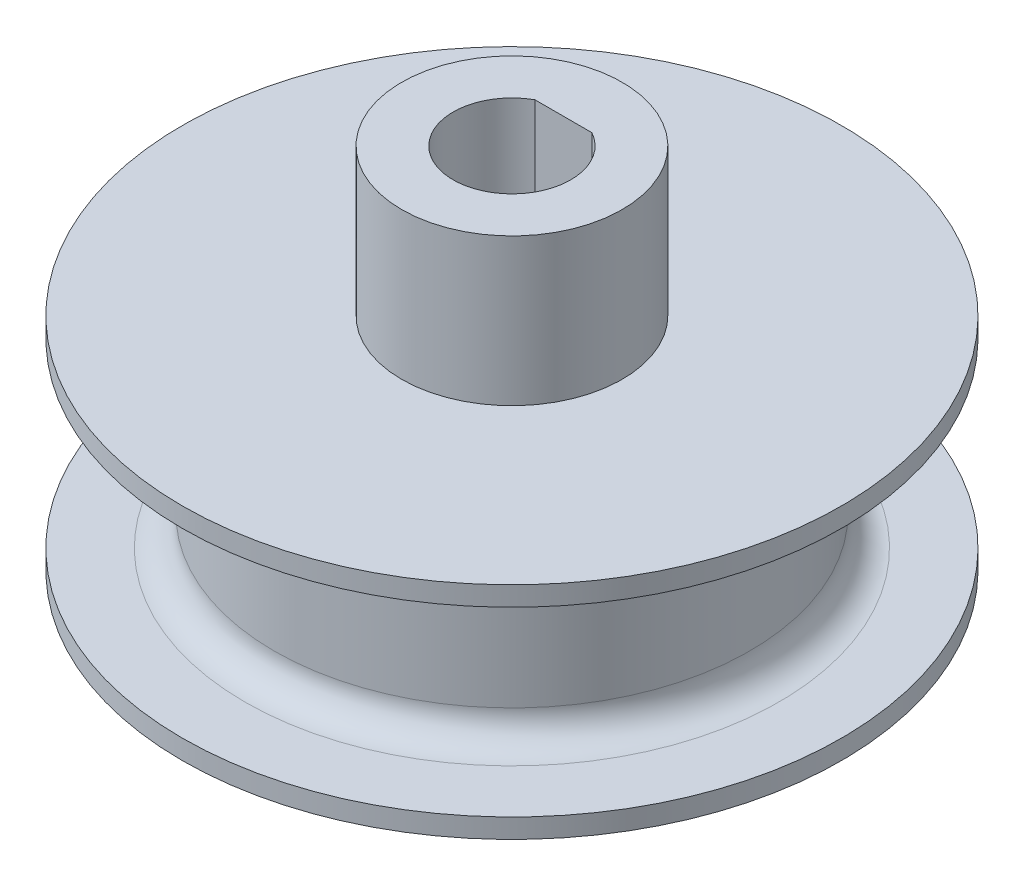
from build123d import *

# Parameters (mm, degrees)
SKETCH2_R           = 15
BOSS_EXTRUDE1_DEPTH = 7.5
SKETCH4_R           = 7.5
BOSS_EXTRUDE2_DEPTH = 10


with BuildPart() as part:
    # Sketch2 → Boss-Extrude1 (new body, symmetric)
    with BuildSketch(Plane(origin=(0, 0, 0), x_dir=(1, 0, 0), z_dir=(0, 1, 0))):
        Circle(SKETCH2_R)
        with BuildLine():
            ThreePointArc((1.936491673, 3.5), (0, -4), (-1.936491673, 3.5))
            Line((-1.936491673, 3.5), (1.936491673, 3.5))
        make_face(mode=Mode.SUBTRACT)
    extrude(amount=BOSS_EXTRUDE1_DEPTH, both=True)

    # Sketch3 → Revolve1 (revolve)
    with BuildSketch(Plane(origin=(0, 0, 0), x_dir=(0, 0, -1), z_dir=(1, 0, 0))):
        with BuildLine():
            ThreePointArc((18.159478483, 6.176007768), (16.745264921, 5.59022133), (16.159478483, 4.176007768))
            Line((16.159478483, 4.176007768), (16.159478483, -4.176007768))
            ThreePointArc((16.159478483, -4.176007768), (16.745264921, -5.59022133), (18.159478483, -6.176007768))
            Line((18.159478483, -6.176007768), (22.413723235, -6.176007768))
            Line((22.413723235, -6.176007768), (22.413723235, -7.5))
            Line((22.413723235, -7.5), (15, -7.5))
            Line((15, -7.5), (15, 7.5))
            Line((15, 7.5), (22.413723235, 7.5))
            Line((22.413723235, 7.5), (22.413723235, 6.176007768))
            Line((22.413723235, 6.176007768), (18.159478483, 6.176007768))
        make_face()
    revolve(axis=Axis((0, 7.5, 0), (0, -1, 0)))

    # Sketch4 → Boss-Extrude2 (add)
    with BuildSketch(Plane(origin=(0, 7.5, 0), x_dir=(1, 0, 0), z_dir=(0, 1, 0))):
        Circle(SKETCH4_R)
        with BuildLine():
            Line((-1.936491673, 3.5), (1.936491673, 3.5))
            ThreePointArc((1.936491673, 3.5), (0, -4), (-1.936491673, 3.5))
        make_face(mode=Mode.SUBTRACT)
    extrude(amount=BOSS_EXTRUDE2_DEPTH)


solid = part.part
